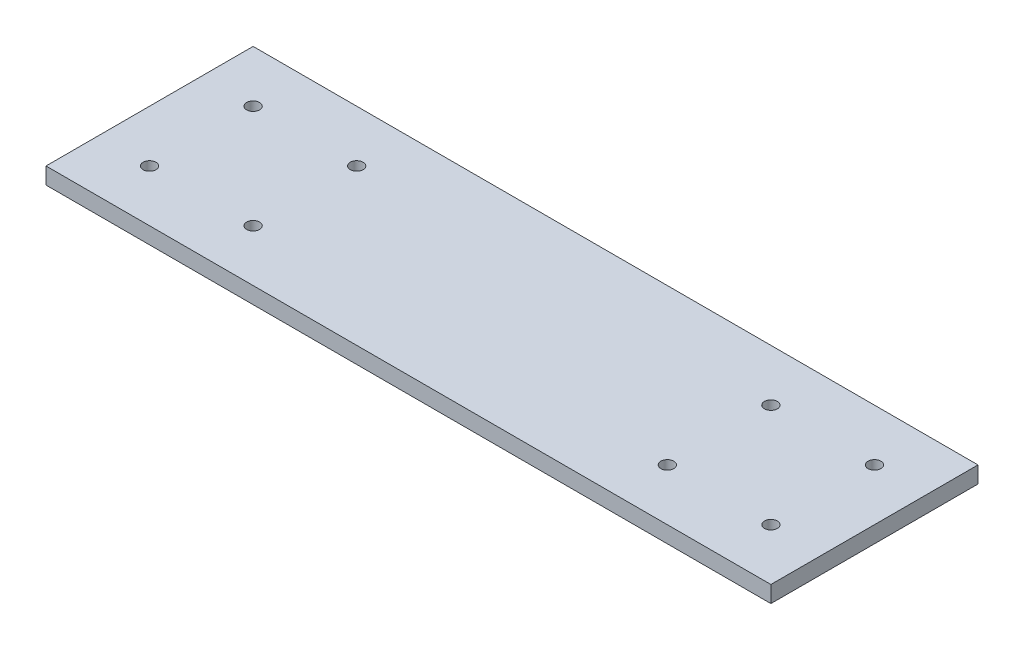
from build123d import *

# Parameters (mm, degrees)
SKETCH1_W                    = 304.8
SKETCH1_H                    = 50.8
BOSS_EXTRUDE1_DEPTH          = 4.064
F_1_8_0_125_DIAMETER_HOLE1_D = 3.175
SKETCH4_W                    = 127
SKETCH4_H                    = 50.8
CUT_EXTRUDE1_DEPTH           = 5.064


with BuildPart() as part:
    # Sketch1 → Boss-Extrude1 (new body)
    with BuildSketch(Plane(origin=(0, 0, 0), x_dir=(1, 0, 0), z_dir=(0, 1, 0))):
        with Locations((152.4, 25.4)):
            Rectangle(SKETCH1_W, SKETCH1_H)
    extrude(amount=BOSS_EXTRUDE1_DEPTH)

    # 1/8 (0.125) Diameter Hole1 (through all)
    with Locations(Plane(origin=(0, 4.064, 0), x_dir=(1, 0, 0), z_dir=(0, 1, 0))):
        with Locations((12.7, 12.7), (38.1, 38.1), (12.7, 38.1), (38.1, 12.7), (139.7, 12.7), (165.1, 38.1), (139.7, 38.1), (165.1, 12.7)):
            Hole(F_1_8_0_125_DIAMETER_HOLE1_D / 2)

    # Sketch4 → Cut-Extrude1 (cut, through all)
    with BuildSketch(Plane(origin=(0, 4.064, 0), x_dir=(1, 0, 0), z_dir=(0, 1, 0))):
        with Locations((241.3, 25.4)):
            Rectangle(SKETCH4_W, SKETCH4_H)
    extrude(amount=-CUT_EXTRUDE1_DEPTH, mode=Mode.SUBTRACT)


solid = part.part
